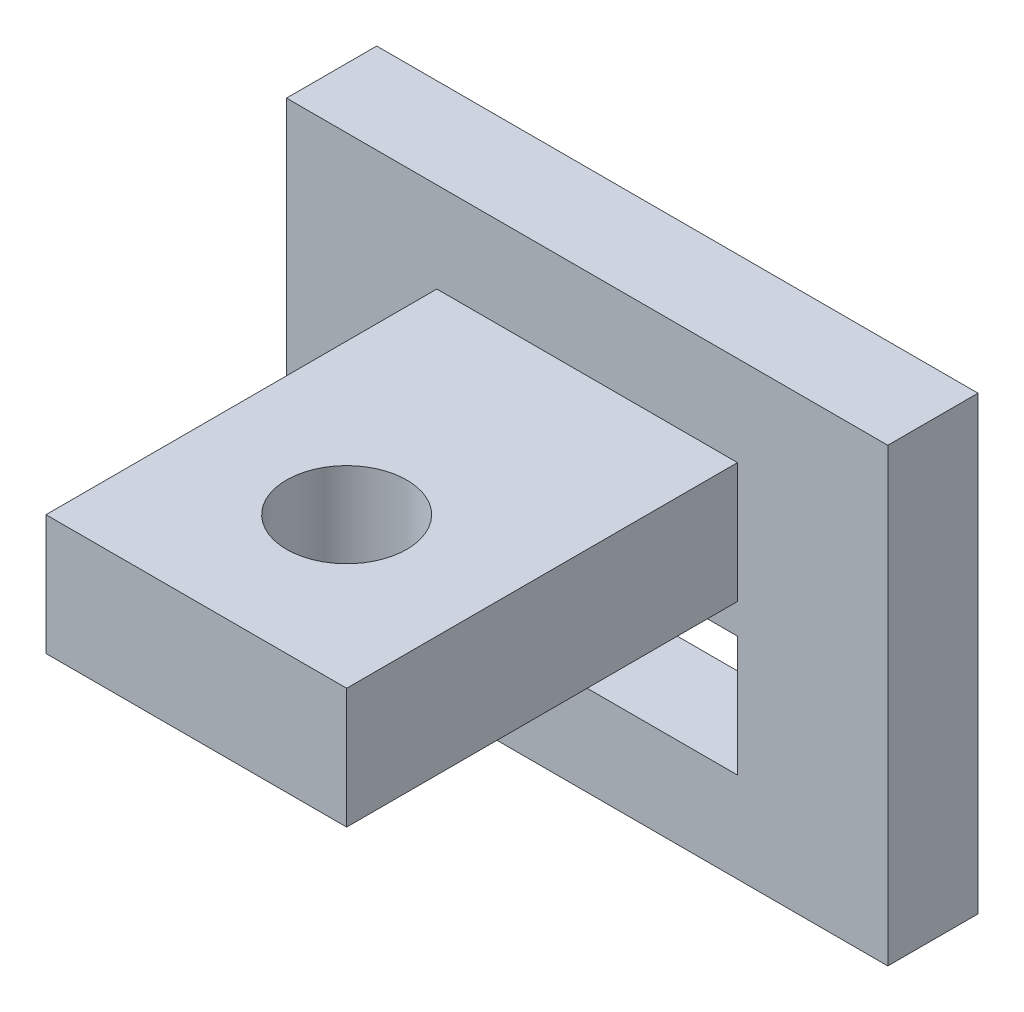
from build123d import *

# Parameters (mm, degrees)
SKETCH1_W           = 20
SKETCH1_H           = 15
BOSS_EXTRUDE1_DEPTH = 3
SKETCH2_W           = 10
SKETCH2_H           = 4
BOSS_EXTRUDE2_DEPTH = 13
SKETCH4_W           = 10
SKETCH4_H           = 4
CUT_EXTRUDE3_DEPTH  = 4
SKETCH3_R           = 2
CUT_EXTRUDE4_DEPTH  = 13


with BuildPart() as part:
    # Sketch1 → Boss-Extrude1 (new body)
    with BuildSketch(Plane.XY):
        with Locations((-10, 7.5)):
            Rectangle(SKETCH1_W, SKETCH1_H)
    extrude(amount=BOSS_EXTRUDE1_DEPTH)

    # Sketch2 → Boss-Extrude2 (add)
    with BuildSketch(Plane.XY.offset(3)):
        with Locations((-10, 10)):
            Rectangle(SKETCH2_W, SKETCH2_H)
    extrude(amount=BOSS_EXTRUDE2_DEPTH)

    # Sketch4 → Cut-Extrude3 (cut, through all)
    with BuildSketch(Plane.XY.offset(3)):
        with Locations((-10, 5)):
            Rectangle(SKETCH4_W, SKETCH4_H)
    extrude(amount=-CUT_EXTRUDE3_DEPTH, mode=Mode.SUBTRACT)

    # Sketch3 → Cut-Extrude4 (cut, through all)
    with BuildSketch(Plane(origin=(0, 12, 0), x_dir=(1, 0, 0), z_dir=(0, 1, 0))):
        with Locations((-10, -11)):
            Circle(SKETCH3_R)
    extrude(amount=-CUT_EXTRUDE4_DEPTH, mode=Mode.SUBTRACT)


solid = part.part
